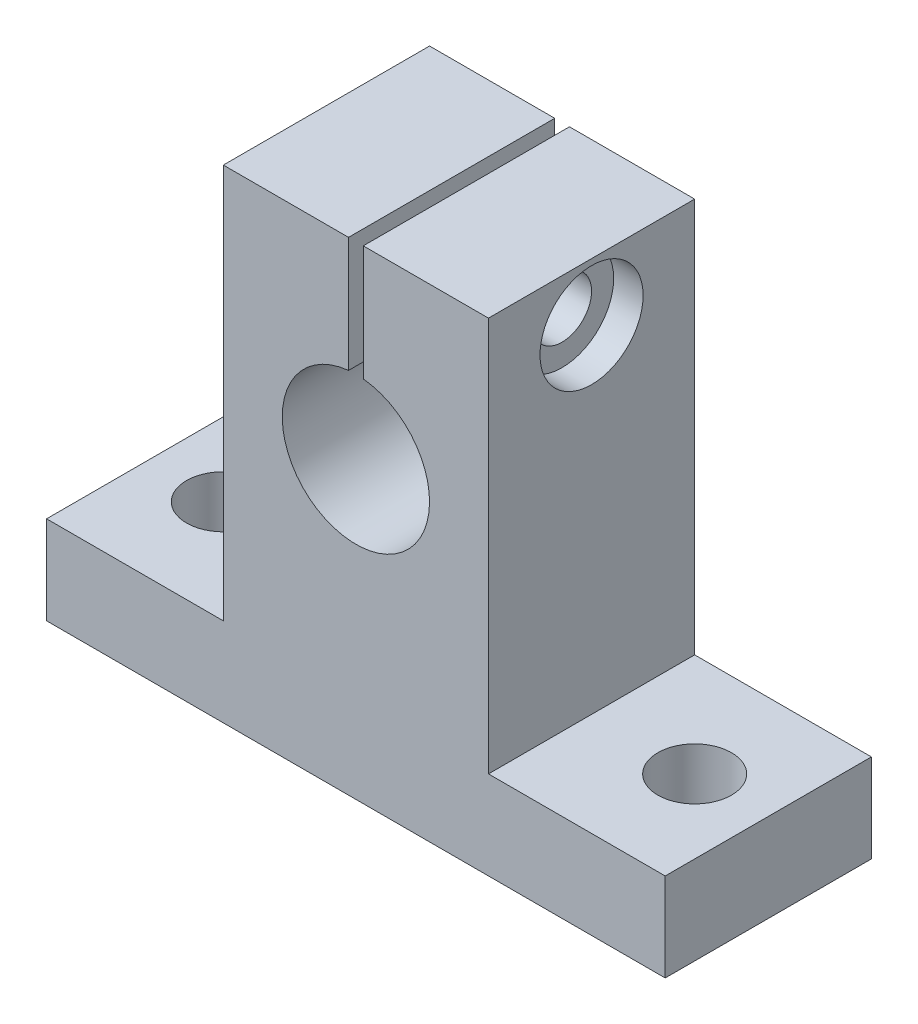
from build123d import *

# Parameters (mm, degrees)
SKETCH_1_R          = 5
EXTRUDE_1_DEPTH     = 14
SKETCH_2_R          = 2.5
CUT_EXTRUDE_1_DEPTH = 7
SKETCH_3_W          = 1
SKETCH_3_H          = 14
CUT_EXTRUDE_2_DEPTH = 14
SKETCH_4_R          = 2
CUT_EXTRUDE_3_DEPTH = 10
SKETCH_5_R          = 3.5
CUT_EXTRUDE_4_DEPTH = 2


with BuildPart() as part:
    # 草图1 → 凸台-拉伸1 (new body)
    with BuildSketch(Plane.XY):
        Polygon((21, 0), (-21, 0), (-21, 6), (-9, 6), (-9, 32.8), (9, 32.8), (9, 6), (21, 6), align=None)
        with Locations((0, 20)):
            Circle(SKETCH_1_R, mode=Mode.SUBTRACT)
    extrude(amount=EXTRUDE_1_DEPTH)

    # 草图2 → 切除-拉伸1 (cut, through all)
    with BuildSketch(Plane(origin=(0, 6, 0), x_dir=(1, 0, 0), z_dir=(0, 1, 0))):
        with Locations((-16, -7)):
            Circle(SKETCH_2_R)
        with Locations((16, -7)):
            Circle(SKETCH_2_R)
    extrude(amount=-CUT_EXTRUDE_1_DEPTH, mode=Mode.SUBTRACT)

    # 草图3 → 切除-拉伸2 (cut)
    with BuildSketch(Plane(origin=(0, 32.8, 0), x_dir=(1, 0, 0), z_dir=(0, 1, 0))):
        with Locations((0, -7)):
            Rectangle(SKETCH_3_W, SKETCH_3_H)
    extrude(amount=-CUT_EXTRUDE_2_DEPTH, mode=Mode.SUBTRACT)

    # 草图4 → 切除-拉伸3 (cut, symmetric)
    with BuildSketch(Plane(origin=(-0.5, 0, 0), x_dir=(0, 0, -1), z_dir=(1, 0, 0))):
        with Locations((-7, 28.887468593)):
            Circle(SKETCH_4_R)
    extrude(amount=CUT_EXTRUDE_3_DEPTH, both=True, mode=Mode.SUBTRACT)

    # 草图5 → 切除-拉伸4 (cut)
    with BuildSketch(Plane(origin=(9, 0, 0), x_dir=(0, 0, -1), z_dir=(1, 0, 0))):
        with Locations((-7, 28.887468593)):
            Circle(SKETCH_5_R)
    extrude(amount=-CUT_EXTRUDE_4_DEPTH, mode=Mode.SUBTRACT)


solid = part.part
